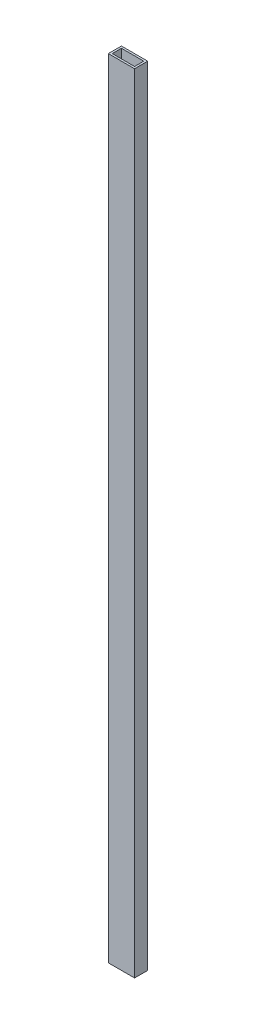
from build123d import *

# Parameters (mm, degrees)
SKETCH_1_W      = 40
SKETCH_1_H      = 20
SKETCH_1_W_2    = 34
SKETCH_1_H_2    = 14
EXTRUDE_1_DEPTH = 1200


with BuildPart() as part:
    # Эскиз1 → Вытянуть-Тонкостенный1 (new body)
    with BuildSketch(Plane(origin=(0, 0, 0), x_dir=(1, 0, 0), z_dir=(0, 1, 0))):
        Rectangle(SKETCH_1_W, SKETCH_1_H)
        Rectangle(SKETCH_1_W_2, SKETCH_1_H_2, mode=Mode.SUBTRACT)
    extrude(amount=EXTRUDE_1_DEPTH)


solid = part.part
